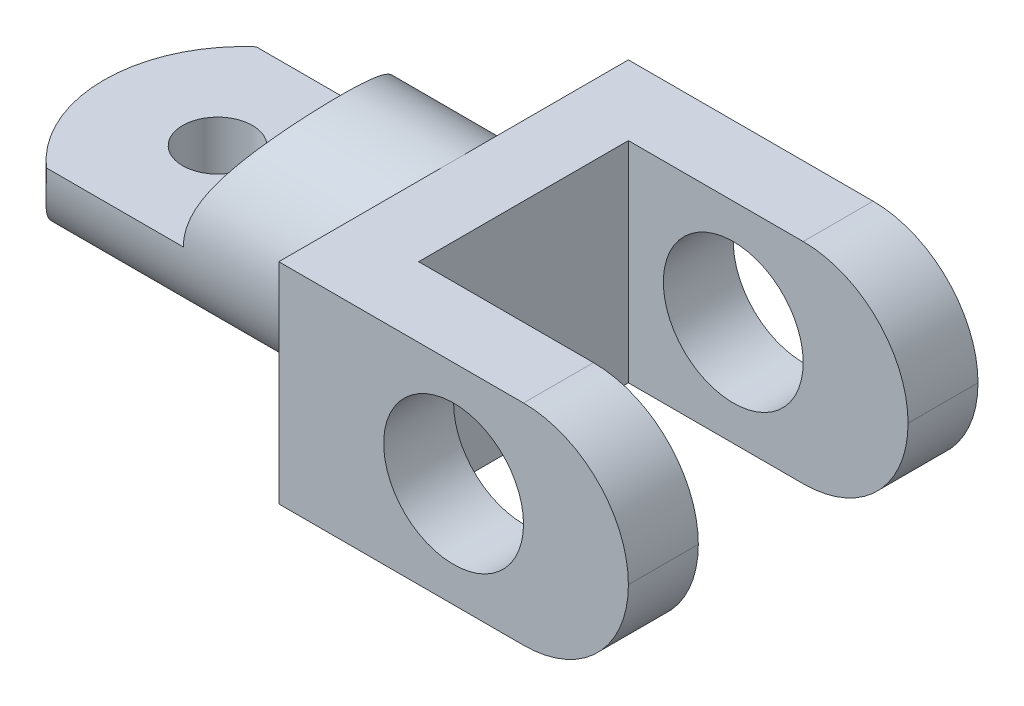
from build123d import *

# Parameters (mm, degrees)
BOSS_EXTRUDE1_DEPTH      = 4.70535
BOSS_EXTRUDE1_DEPTH_BACK = 4.70535
SKETCH2_R                = 4.70535
BOSS_EXTRUDE2_DEPTH      = 17.25168
CUT_EXTRUDE3_DEPTH       = 10.4107
SKETCH5_R                = 5.900934737
CUT_EXTRUDE4_DEPTH       = 4.70408
SKETCH6_R                = 1.56718
CUT_EXTRUDE5_DEPTH       = 5.706620123
FILLET1_R                = 4.70408
SKETCH7_R                = 3.1369
CUT_EXTRUDE6_DEPTH       = 16.68196


with BuildPart() as part:
    # Sketch1 → Boss-Extrude1 (new body, two sides)
    with BuildSketch(Plane(origin=(0, 0, 0), x_dir=(1, 0, 0), z_dir=(0, 1, 0))) as boss_extrude1_sk:
        Polygon((-12.54506, 4.70408), (0, 4.70408), (0, 7.84098), (-15.68196, 7.84098), (-15.68196, -7.84098), (0, -7.84098), (0, -4.70408), (-12.54506, -4.70408), align=None)
    extrude(amount=BOSS_EXTRUDE1_DEPTH)
    extrude(boss_extrude1_sk.sketch, amount=-BOSS_EXTRUDE1_DEPTH_BACK)

    # Sketch2 → Boss-Extrude2 (add)
    with BuildSketch(Plane.ZY.offset(15.68196)):
        Circle(SKETCH2_R)
    extrude(amount=BOSS_EXTRUDE2_DEPTH)

    # Sketch3 → Cut-Extrude3 (cut, through all)
    with BuildSketch(Plane(origin=(0, 4.70535, 0), x_dir=(1, 0, 0), z_dir=(0, 1, 0))):
        with BuildLine():
            Line((-25.09266, 6.2738), (-33.67290655, 6.2738))
            Line((-33.67290655, 6.2738), (-33.67290655, -6.2738))
            Line((-33.67290655, -6.2738), (-25.09266, -6.2738))
            ThreePointArc((-25.09266, -6.2738), (-31.36646, 0), (-25.09266, 6.2738))
        make_face()
    extrude(amount=-CUT_EXTRUDE3_DEPTH, mode=Mode.SUBTRACT)

    # Sketch5 → Cut-Extrude4 (cut)
    with BuildSketch(Plane(origin=(0, 4.70535, 0), x_dir=(1, 0, 0), z_dir=(0, 1, 0))):
        with Locations((-26.65984, 0)):
            Circle(SKETCH5_R)
    extrude(amount=-CUT_EXTRUDE4_DEPTH, mode=Mode.SUBTRACT)

    # Sketch6 → Cut-Extrude5 (cut, through all)
    with BuildSketch(Plane(origin=(0, 0.00127, 0), x_dir=(1, 0, 0), z_dir=(0, 1, 0))):
        with Locations((-26.26868, 0)):
            Circle(SKETCH6_R)
    extrude(amount=-CUT_EXTRUDE5_DEPTH, mode=Mode.SUBTRACT)

    # Fillet1
    fillet1_edges = [part.edges().sort_by_distance(p)[0] for p in [
        (0, -4.70535, -6.27253),
        (0, -4.70535, 6.27253),
        (0, 4.70535, -6.27253),
        (0, 4.70535, 6.27253),
    ]]
    fillet(fillet1_edges, radius=FILLET1_R)

    # Sketch7 → Cut-Extrude6 (cut, through all)
    with BuildSketch(Plane.XY.offset(7.84098)):
        with Locations((-7.84098, 0)):
            Circle(SKETCH7_R)
    extrude(amount=-CUT_EXTRUDE6_DEPTH, mode=Mode.SUBTRACT)


solid = part.part
